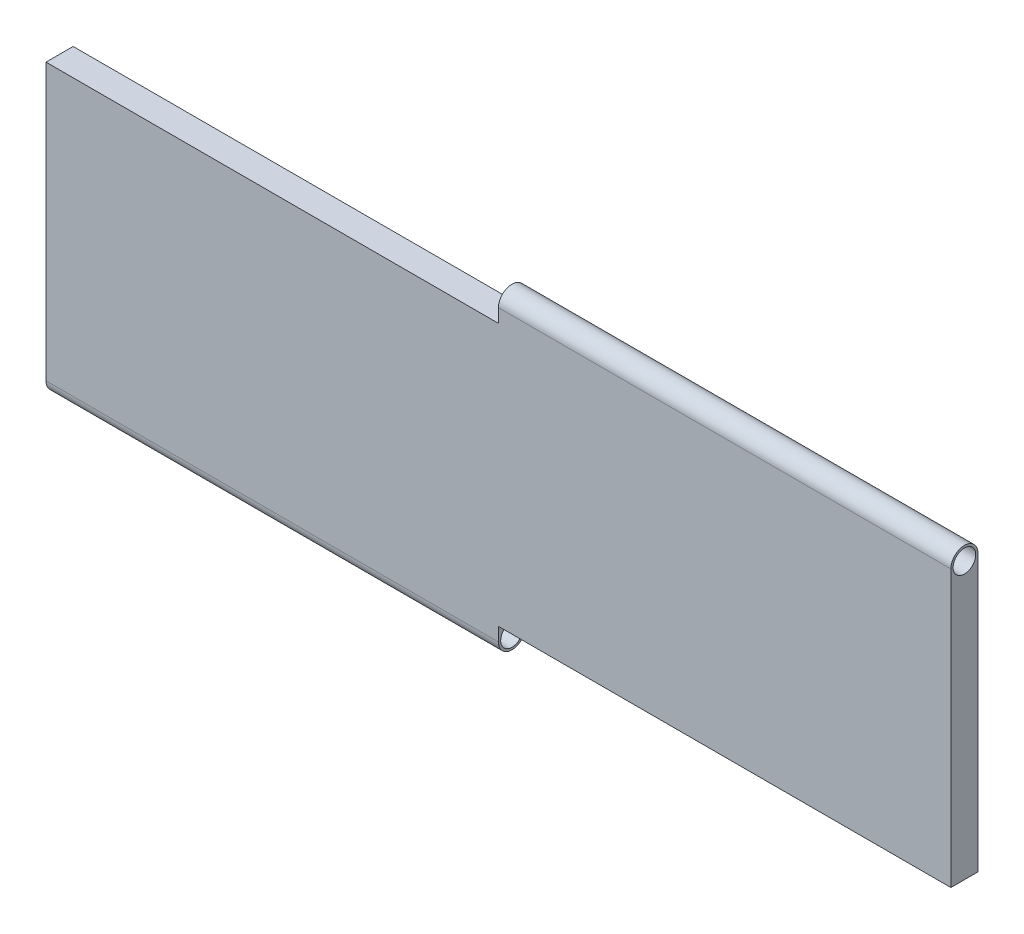
from build123d import *

# Parameters (mm, degrees)
SKETCH1_W           = 1000
SKETCH1_H           = 290
BOSS_EXTRUDE1_DEPTH = 30
SKETCH2_R           = 15
SKETCH2_R_2         = 12.5
BOSS_EXTRUDE2_DEPTH = 500
SKETCH3_R           = 15
SKETCH3_R_2         = 12.5
BOSS_EXTRUDE3_DEPTH = 500


with BuildPart() as part:
    # Sketch1 → Boss-Extrude1 (new body)
    with BuildSketch(Plane.XY):
        Rectangle(SKETCH1_W, SKETCH1_H)
    extrude(amount=BOSS_EXTRUDE1_DEPTH)

    # Sketch2 → Boss-Extrude2 (add)
    with BuildSketch(Plane(origin=(500, 0, 0), x_dir=(0, 0, -1), z_dir=(1, 0, 0))):
        with Locations((-15, 160)):
            Circle(SKETCH2_R)
        with Locations((-15, 160)):
            Circle(SKETCH2_R_2, mode=Mode.SUBTRACT)
        with BuildLine():
            ThreePointArc((-15, 145), (-25.606601718, 149.393398282), (-30, 160))
            Line((-30, 160), (-30, 145))
            Line((-30, 145), (-15, 145))
        make_face()
        with BuildLine():
            Line((0, 145), (0, 160))
            ThreePointArc((0, 160), (-4.393398282, 149.393398282), (-15, 145))
            Line((-15, 145), (0, 145))
        make_face()
    extrude(amount=-BOSS_EXTRUDE2_DEPTH)

    # Sketch3 → Boss-Extrude3 (add)
    with BuildSketch(Plane.ZY.offset(500)):
        with BuildLine():
            Line((0, -145), (0, -160))
            ThreePointArc((0, -160), (4.393398282, -149.393398282), (15, -145))
            Line((15, -145), (0, -145))
        make_face()
        with Locations((15, -160)):
            Circle(SKETCH3_R)
        with Locations((15, -160)):
            Circle(SKETCH3_R_2, mode=Mode.SUBTRACT)
        with BuildLine():
            ThreePointArc((15, -145), (25.606601718, -149.393398282), (30, -160))
            Line((30, -160), (30, -145))
            Line((30, -145), (15, -145))
        make_face()
    extrude(amount=-BOSS_EXTRUDE3_DEPTH)


solid = part.part
